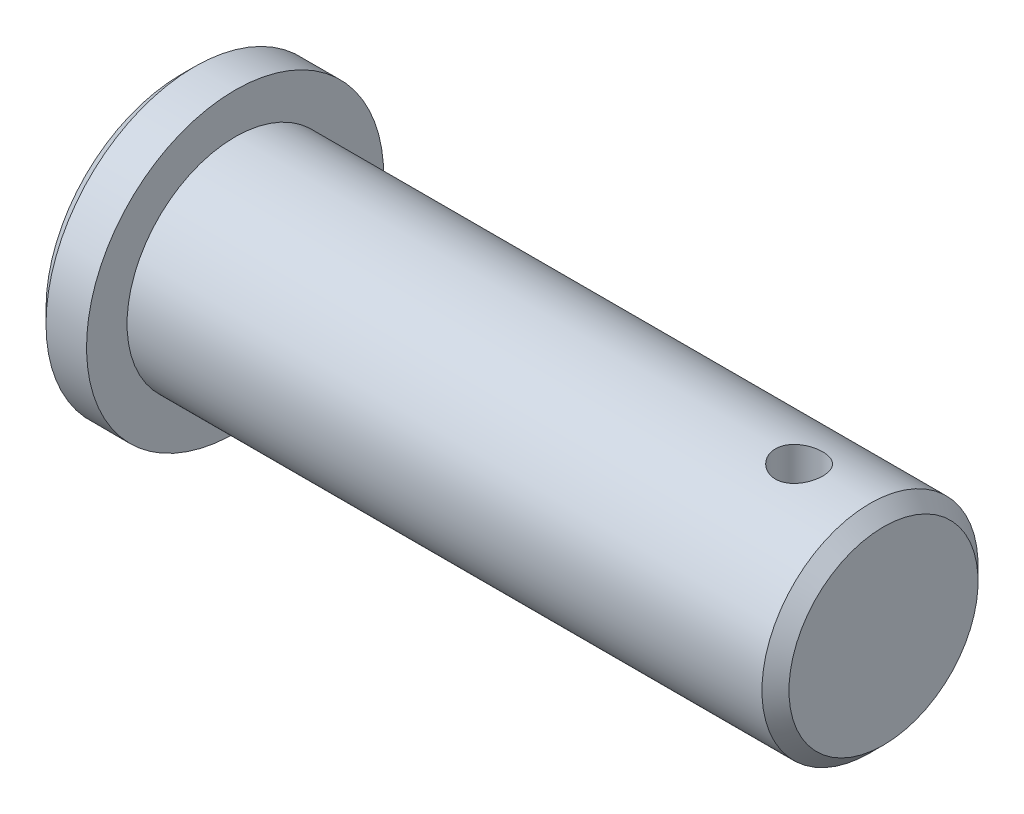
from build123d import *

# Parameters (mm, degrees)
SZKIC2_R                        = 1.75
WYTNIJ_WYCI_GNI_CIE1_DEPTH      = 12
WYTNIJ_WYCI_GNI_CIE1_DEPTH_BACK = 12
SFAZOWANIE1_SIZE                = 1


with BuildPart() as part:
    # Szkic1 → Obrót1 (revolve)
    with BuildSketch(Plane.XY):
        Polygon((0, 0), (0, 11), (4, 11), (4, 8), (52, 8), (52, 0), align=None)
    revolve(axis=Axis((52, 0, 0), (-1, 0, 0)))

    # Szkic2 → Wytnij-wyciągnięcie1 (cut, two sides)
    with BuildSketch(Plane(origin=(0, 0, 0), x_dir=(1, 0, 0), z_dir=(0, 1, 0))) as wytnij_wyci_gni_cie1_sk:
        with Locations((45.75, 0)):
            Circle(SZKIC2_R)
    extrude(amount=WYTNIJ_WYCI_GNI_CIE1_DEPTH, mode=Mode.SUBTRACT)
    extrude(wytnij_wyci_gni_cie1_sk.sketch, amount=-WYTNIJ_WYCI_GNI_CIE1_DEPTH_BACK, mode=Mode.SUBTRACT)

    # Sfazowanie1
    sfazowanie1_edges = [part.edges().sort_by_distance(p)[0] for p in [
        (52, -8, 0),
        (0, -11, 0),
    ]]
    chamfer(sfazowanie1_edges, length=SFAZOWANIE1_SIZE)


solid = part.part
